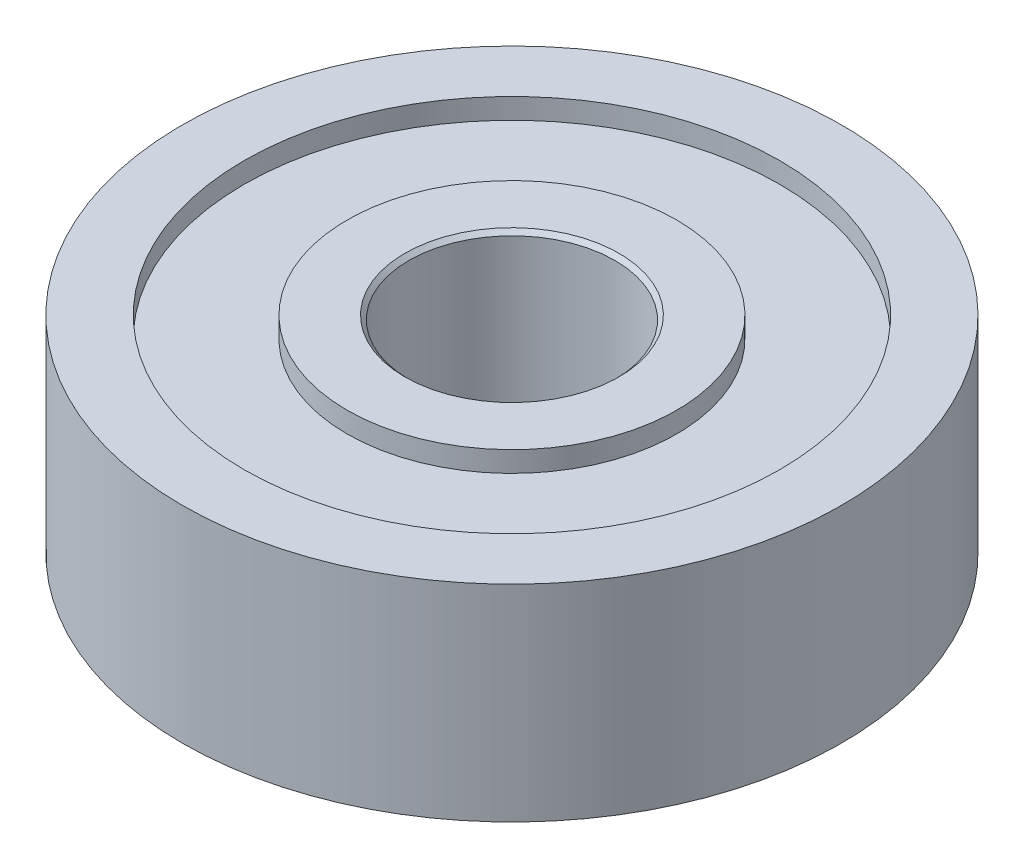
from build123d import *

# Parameters (mm, degrees)
SKETCH1_R           = 8
SKETCH1_R_2         = 2.5
BOSS_EXTRUDE1_DEPTH = 2.5
SKETCH2_R           = 6.5
SKETCH2_R_2         = 4
CUT_EXTRUDE1_DEPTH  = 0.5
CHAMFER1_SIZE       = 0.1


with BuildPart() as part:
    # Sketch1 → Boss-Extrude1 (new body, symmetric)
    with BuildSketch(Plane(origin=(0, 0, 0), x_dir=(1, 0, 0), z_dir=(0, 1, 0))):
        Circle(SKETCH1_R)
        Circle(SKETCH1_R_2, mode=Mode.SUBTRACT)
    extrude(amount=BOSS_EXTRUDE1_DEPTH, both=True)

    # Sketch2 → Cut-Extrude1 (cut)
    with BuildSketch(Plane(origin=(0, 2.5, 0), x_dir=(1, 0, 0), z_dir=(0, 1, 0))):
        Circle(SKETCH2_R)
        Circle(SKETCH2_R_2, mode=Mode.SUBTRACT)
    cut_extrude1 = extrude(amount=-CUT_EXTRUDE1_DEPTH, mode=Mode.SUBTRACT)

    # Mirror1: Cut-Extrude1 across plane
    add(cut_extrude1.mirror(Plane.ZX), mode=Mode.SUBTRACT)

    # Chamfer1
    chamfer1_edges = [part.edges().sort_by_distance(p)[0] for p in [
        (-2.5, -2.5, 0),
        (-2.5, 2.5, 0),
    ]]
    chamfer(chamfer1_edges, length=CHAMFER1_SIZE)


solid = part.part
